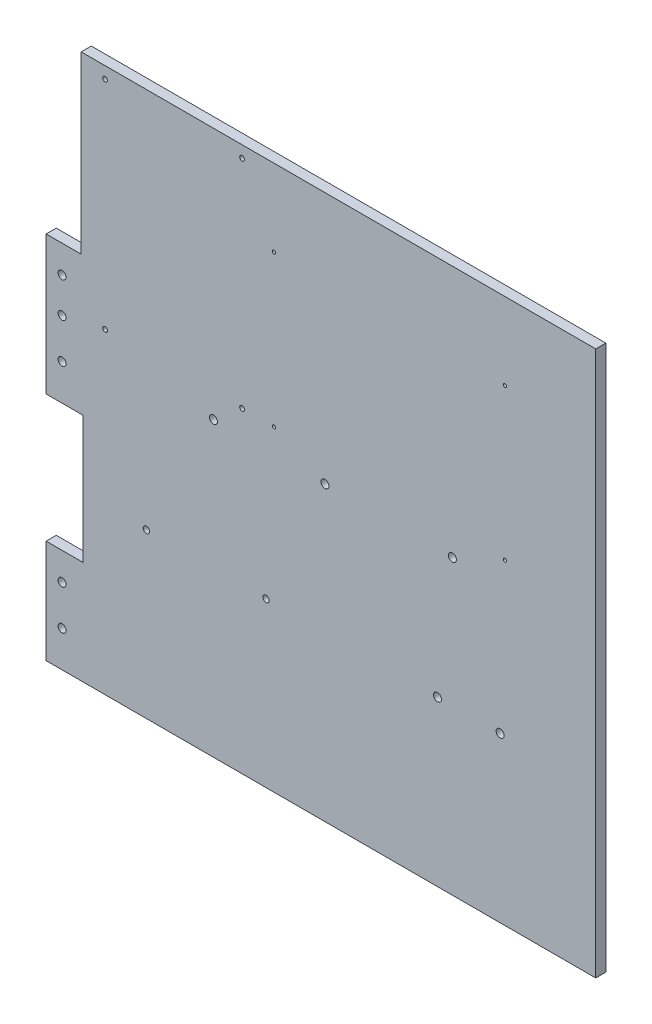
from build123d import *

# Parameters (mm, degrees)
MODEL_R             = 2.5
MODEL_R_2           = 2
MODEL_R_3           = 1.5
MODEL_R_4           = 1.05
BOSS_EXTRUDE1_DEPTH = 6.35


with BuildPart() as part:
    # Model → Boss-Extrude1 (new body)
    with BuildSketch(Plane.XY):
        Polygon((731.320358487, 258.065863271), (386.320358487, 258.065863271), (386.320358487, 323.065863271), (409.320358487, 323.065863271), (409.320358487, 403.065863271), (386.320358487, 403.065863271), (386.320358487, 490.065863271), (408.320358487, 490.065863271), (408.320358487, 600.065863271), (731.320358487, 600.065863271), align=None)
        with Locations((396.320358487, 472.687351768)):
            Circle(MODEL_R, mode=Mode.SUBTRACT)
        with Locations((396.320358487, 450.687351768)):
            Circle(MODEL_R, mode=Mode.SUBTRACT)
        with Locations((396.320358487, 425.687351768)):
            Circle(MODEL_R, mode=Mode.SUBTRACT)
        with Locations((396.320358487, 305.687351768)):
            Circle(MODEL_R, mode=Mode.SUBTRACT)
        with Locations((396.320358487, 280.687351768)):
            Circle(MODEL_R, mode=Mode.SUBTRACT)
        with Locations((491.320358487, 441.687351768)):
            Circle(MODEL_R, mode=Mode.SUBTRACT)
        with Locations((561.320358487, 441.687351768)):
            Circle(MODEL_R, mode=Mode.SUBTRACT)
        with Locations((641.320358487, 441.687351768)):
            Circle(MODEL_R, mode=Mode.SUBTRACT)
        with Locations((449.26902181, 360.687351768)):
            Circle(MODEL_R_2, mode=Mode.SUBTRACT)
        with Locations((524.320358487, 360.687351768)):
            Circle(MODEL_R_2, mode=Mode.SUBTRACT)
        with Locations((423.320358487, 592.687351768)):
            Circle(MODEL_R_3, mode=Mode.SUBTRACT)
        with Locations((509.320358487, 592.687351768)):
            Circle(MODEL_R_3, mode=Mode.SUBTRACT)
        with Locations((509.320358487, 456.687351768)):
            Circle(MODEL_R_3, mode=Mode.SUBTRACT)
        with Locations((423.320358487, 456.687351768)):
            Circle(MODEL_R_3, mode=Mode.SUBTRACT)
        with Locations((529.320358487, 551.687351768)):
            Circle(MODEL_R_4, mode=Mode.SUBTRACT)
        with Locations((674.320358487, 551.687351768)):
            Circle(MODEL_R_4, mode=Mode.SUBTRACT)
        with Locations((529.320358487, 456.687351768)):
            Circle(MODEL_R_4, mode=Mode.SUBTRACT)
        with Locations((674.320358487, 456.687351768)):
            Circle(MODEL_R_4, mode=Mode.SUBTRACT)
        with Locations((631.970358487, 361.072616848)):
            Circle(MODEL_R, mode=Mode.SUBTRACT)
        with Locations((671.320358487, 361.072616848)):
            Circle(MODEL_R, mode=Mode.SUBTRACT)
    extrude(amount=-BOSS_EXTRUDE1_DEPTH)


solid = part.part
